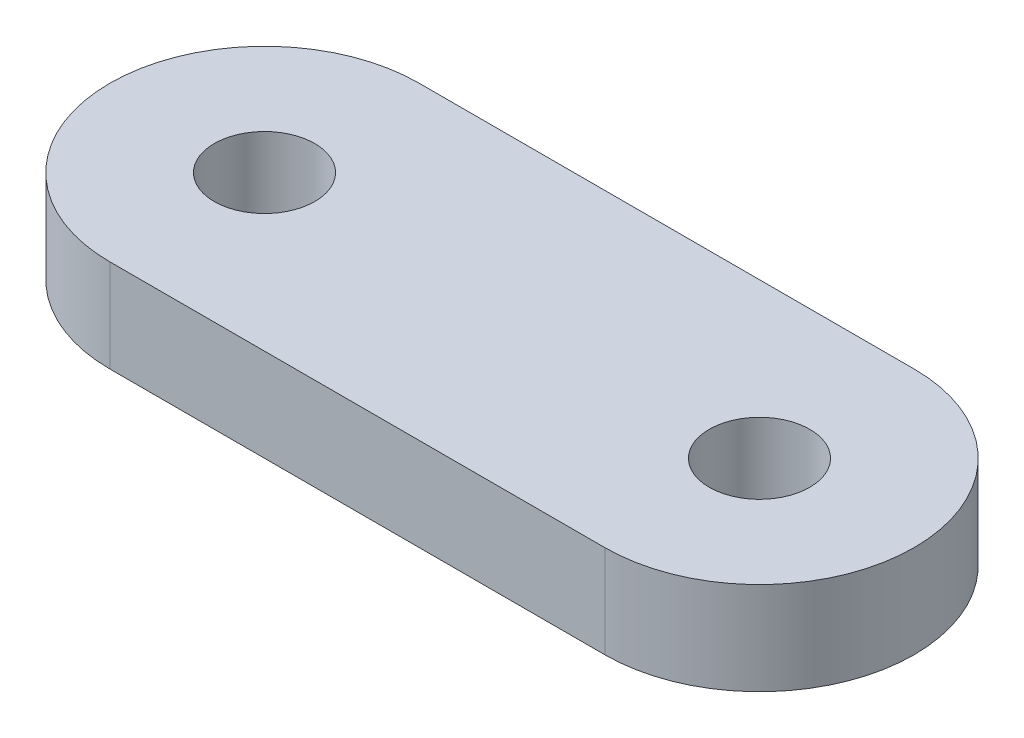
from build123d import *

# Parameters (mm, degrees)
SKETCH1_R           = 1.625
BOSS_EXTRUDE1_DEPTH = 3


with BuildPart() as part:
    # Sketch1 → Boss-Extrude1 (new body)
    with BuildSketch(Plane(origin=(0, 0, 0), x_dir=(1, 0, 0), z_dir=(0, 1, 0))):
        with BuildLine():
            Line((0, 5), (16, 5))
            ThreePointArc((16, 5), (21, 0), (16, -5))
            Line((16, -5), (0, -5))
            ThreePointArc((0, -5), (-5, 0), (0, 5))
        make_face()
        Circle(SKETCH1_R, mode=Mode.SUBTRACT)
        with Locations((16, 0)):
            Circle(SKETCH1_R, mode=Mode.SUBTRACT)
    extrude(amount=BOSS_EXTRUDE1_DEPTH)


solid = part.part
